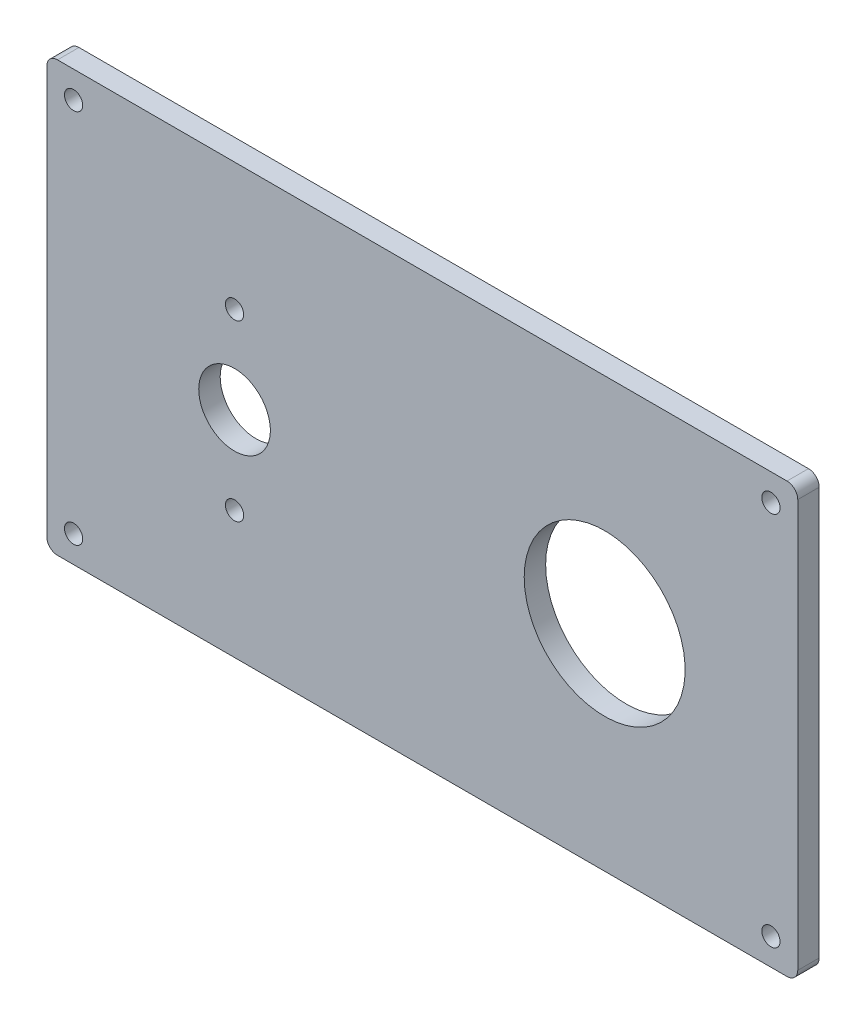
from build123d import *

# Parameters (mm, degrees)
SKETCH1_W           = 140
SKETCH1_H           = 80
BOSS_EXTRUDE1_DEPTH = 4
SKETCH2_R           = 6.675
SKETCH2_R_2         = 1.7
SKETCH2_R_3         = 15
CUT_EXTRUDE1_DEPTH  = 4
FILLET1_R           = 2


with BuildPart() as part:
    # Sketch1 → Boss-Extrude1 (new body)
    with BuildSketch(Plane.XY):
        with Locations((68.890553518, -1.461144776)):
            Rectangle(SKETCH1_W, SKETCH1_H)
    extrude(amount=BOSS_EXTRUDE1_DEPTH)

    # Sketch2 → Cut-Extrude1 (cut)
    with BuildSketch(Plane(origin=(0, 0, 0), x_dir=(-1, 0, 0), z_dir=(0, 0, -1))):
        with Locations((-33.890553518, -1.461144776)):
            Circle(SKETCH2_R)
        with Locations((-33.890553518, 14.758855224)):
            Circle(SKETCH2_R_2)
        with Locations((-33.890553518, -17.681144776)):
            Circle(SKETCH2_R_2)
        with Locations((-3.890553518, -36.461144776)):
            Circle(SKETCH2_R_2)
        with Locations((-133.890553518, -36.461144776)):
            Circle(SKETCH2_R_2)
        with Locations((-133.890553518, 33.538855224)):
            Circle(SKETCH2_R_2)
        with Locations((-3.890553518, 33.538855224)):
            Circle(SKETCH2_R_2)
        with Locations((-102.890553518, -1.461144776)):
            Circle(SKETCH2_R_3)
    extrude(amount=-CUT_EXTRUDE1_DEPTH, mode=Mode.SUBTRACT)

    # Fillet1
    fillet1_edges = [part.edges().sort_by_distance(p)[0] for p in [
        (-1.109446482, 38.538855224, 2),
        (138.890553518, 38.538855224, 2),
        (138.890553518, -41.461144776, 2),
        (-1.109446482, -41.461144776, 2),
    ]]
    fillet(fillet1_edges, radius=FILLET1_R)


solid = part.part
